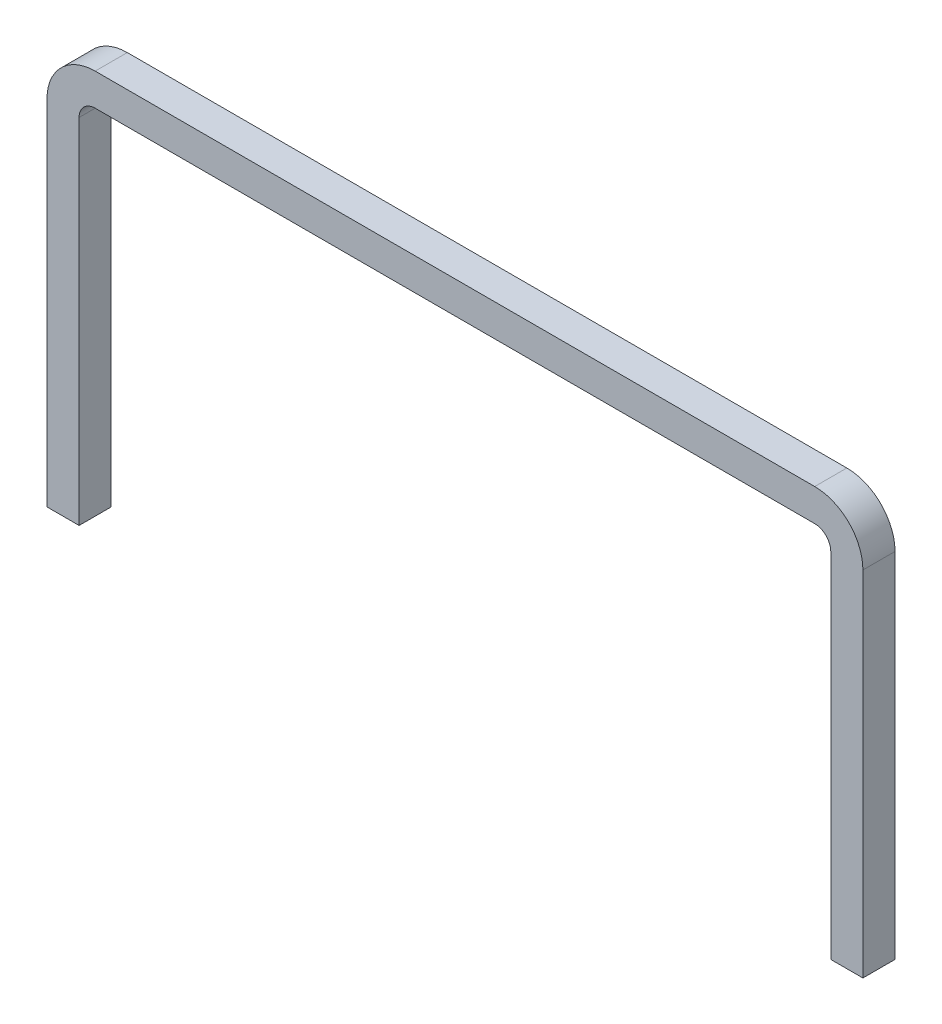
from build123d import *

# Parameters (mm, degrees)
EXTRUDE_THIN2_DEPTH = 0.25


with BuildPart() as part:
    # Sketch1 → Extrude-Thin2 (new body, symmetric)
    with BuildSketch(Plane.XY):
        with BuildLine():
            Line((-5.85, -5.5), (-5.85, 0))
            ThreePointArc((-5.85, 0), (-5.776776695, 0.176776695), (-5.6, 0.25))
            Line((-5.6, 0.25), (5.6, 0.25))
            ThreePointArc((5.6, 0.25), (5.776776695, 0.176776695), (5.85, 0))
            Line((5.85, 0), (5.85, -5.5))
            Line((5.85, -5.5), (6.35, -5.5))
            Line((6.35, -5.5), (6.35, 0))
            ThreePointArc((6.35, 0), (6.130330086, 0.530330086), (5.6, 0.75))
            Line((5.6, 0.75), (-5.6, 0.75))
            ThreePointArc((-5.6, 0.75), (-6.130330086, 0.530330086), (-6.35, 0))
            Line((-6.35, 0), (-6.35, -5.5))
            Line((-6.35, -5.5), (-5.85, -5.5))
        make_face()
    extrude(amount=EXTRUDE_THIN2_DEPTH, both=True)


solid = part.part
